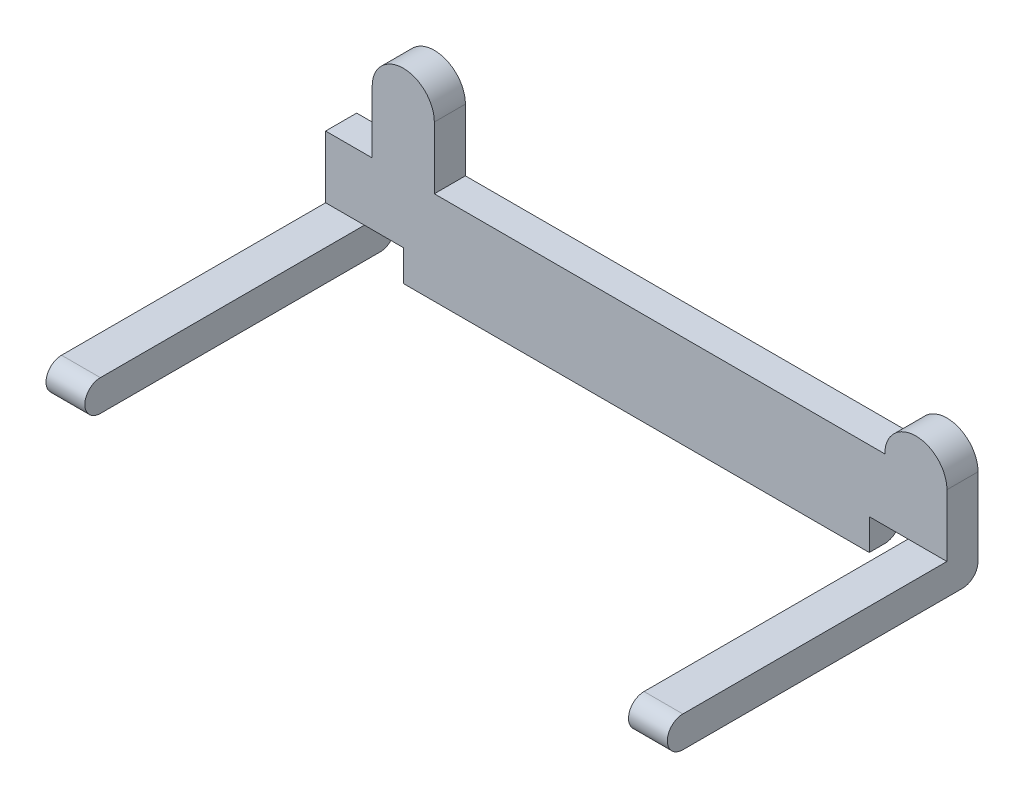
from build123d import *

# Parameters (mm, degrees)
EXTRUDE_1_DEPTH     = 80
SKETCH_10_W         = 4
SKETCH_10_H         = 8
EXTRUDE_8_DEPTH     = 80
EXTRUDE_9_DEPTH     = 4
SKETCH_12_W         = 70
SKETCH_12_H         = 40.815900945
CUT_EXTRUDE_1_DEPTH = 10
SKETCH_13_W         = 5
SKETCH_13_H         = 4
CUT_EXTRUDE_2_DEPTH = 10


with BuildPart() as part:
    # 草图1 → 凸台-拉伸1 (new body)
    with BuildSketch(Plane(origin=(0, 0, 0), x_dir=(0, 0, -1), z_dir=(1, 0, 0))):
        with BuildLine():
            Line((-18, 2), (18, 2))
            Line((18, 2), (20, 2))
            Line((20, 2), (20, 0))
            ThreePointArc((20, 0), (19.414213562, -1.414213562), (18, -2))
            Line((18, -2), (-18, -2))
            ThreePointArc((-18, -2), (-20, 0), (-18, 2))
        make_face()
    extrude(amount=EXTRUDE_1_DEPTH)

    # 草图10 → 凸台-拉伸8 (add)
    with BuildSketch(Plane(origin=(80, 0, 0), x_dir=(0, 0, -1), z_dir=(1, 0, 0))):
        with Locations((18, 6)):
            Rectangle(SKETCH_10_W, SKETCH_10_H)
    extrude(amount=-EXTRUDE_8_DEPTH)

    # 草图11 → 凸台-拉伸9 (add)
    with BuildSketch(Plane(origin=(0, 0, -20), x_dir=(-1, 0, 0), z_dir=(0, 0, -1))):
        with BuildLine():
            Line((-6, 10), (-14, 10))
            Line((-14, 10), (-14, 18))
            ThreePointArc((-14, 18), (-10, 22), (-6, 18))
            Line((-6, 18), (-6, 10))
        make_face()
        with BuildLine():
            Line((-72, 6), (-80, 6))
            Line((-80, 6), (-80, 10))
            ThreePointArc((-80, 10), (-76, 14), (-72, 10))
            Line((-72, 10), (-72, 6))
        make_face()
    extrude(amount=-EXTRUDE_9_DEPTH)

    # 草图12 → 切除-拉伸1 (cut)
    with BuildSketch(Plane(origin=(0, 2, 0), x_dir=(1, 0, 0), z_dir=(0, 1, 0))):
        with Locations((40, -4.407950473)):
            Rectangle(SKETCH_12_W, SKETCH_12_H)
    extrude(amount=-CUT_EXTRUDE_1_DEPTH, mode=Mode.SUBTRACT)

    # 草图13 → 切除-拉伸2 (cut)
    with BuildSketch(Plane.XY.offset(-16)):
        with Locations((7.5, 0)):
            Rectangle(SKETCH_13_W, SKETCH_13_H)
        with Locations((72.5, 0)):
            Rectangle(SKETCH_13_W, SKETCH_13_H)
    extrude(amount=-CUT_EXTRUDE_2_DEPTH, mode=Mode.SUBTRACT)


solid = part.part
